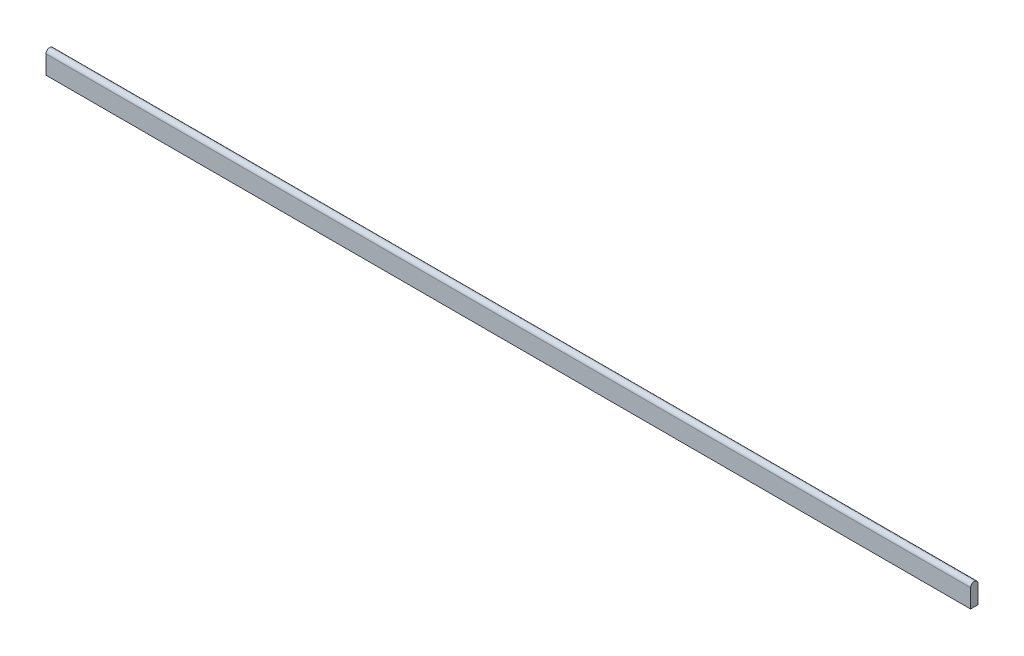
from build123d import *

# Parameters (mm, degrees)
EXTRUSION1_DEPTH = 500


with BuildPart() as part:
    # Esquisse1 → Extrusion1 (new body)
    with BuildSketch(Plane(origin=(0, 0, 0), x_dir=(0, 0, -1), z_dir=(1, 0, 0))):
        with BuildLine():
            Line((-2, 0), (-2, -10))
            Line((-2, -10), (2, -10))
            Line((2, -10), (2, 0))
            ThreePointArc((2, 0), (0, 2), (-2, 0))
        make_face()
    extrude(amount=EXTRUSION1_DEPTH)


solid = part.part
